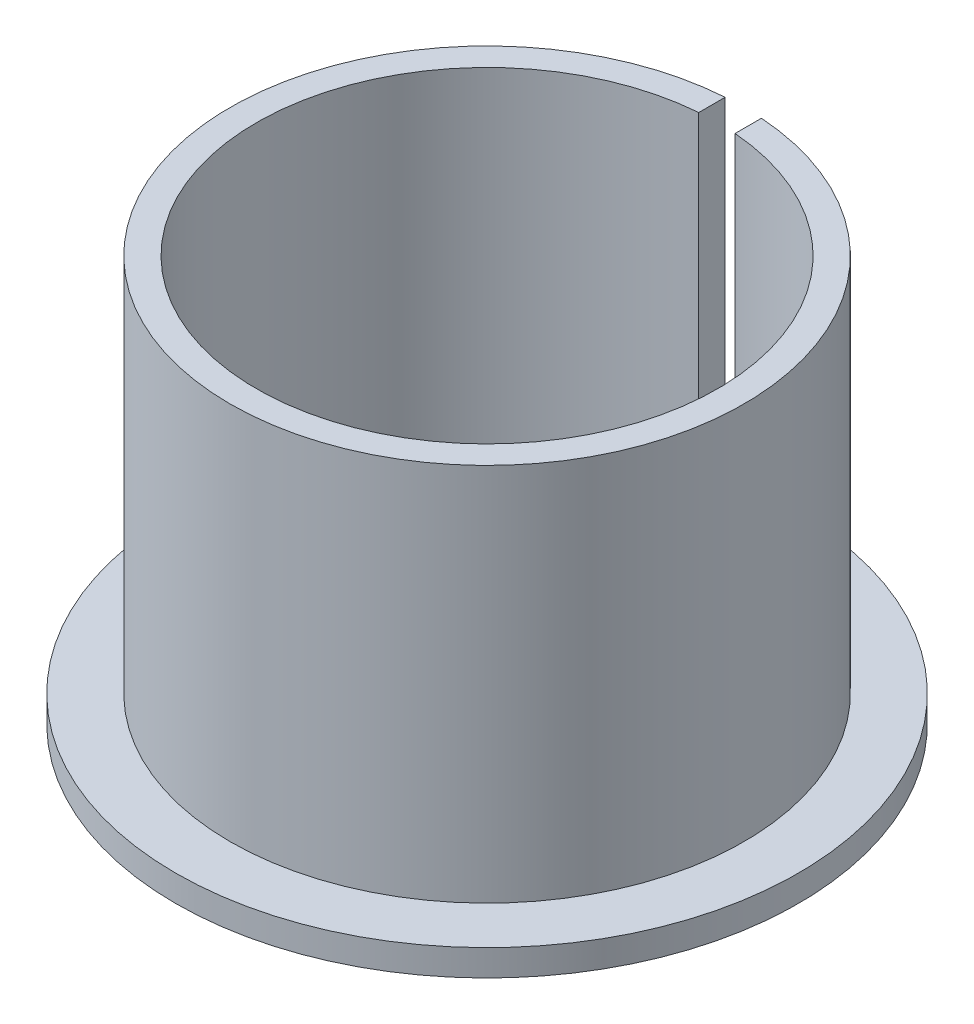
from build123d import *

# Parameters (mm, degrees)
SKETCH2_W          = 2
SKETCH2_H          = 66.093473653
CUT_EXTRUDE1_DEPTH = 23.33


with BuildPart() as part:
    # Sketch1 → Revolve1 (revolve)
    with BuildSketch(Plane.XY):
        Polygon((12.7, 2.789418738), (12.7, 25.119418738), (14.15, 25.119418738), (14.15, 4.239418738), (17.15, 4.239418738), (17.15, 2.789418738), align=None)
    revolve(axis=Axis((0, 0, 0), (0, 1, 0)))

    # Sketch2 → Cut-Extrude1 (cut, through all)
    with BuildSketch(Plane(origin=(0, 25.119418738, 0), x_dir=(1, 0, 0), z_dir=(0, 1, 0))):
        with Locations((0, 26.994107081)):
            Rectangle(SKETCH2_W, SKETCH2_H)
    extrude(amount=-CUT_EXTRUDE1_DEPTH, mode=Mode.SUBTRACT)


solid = part.part
